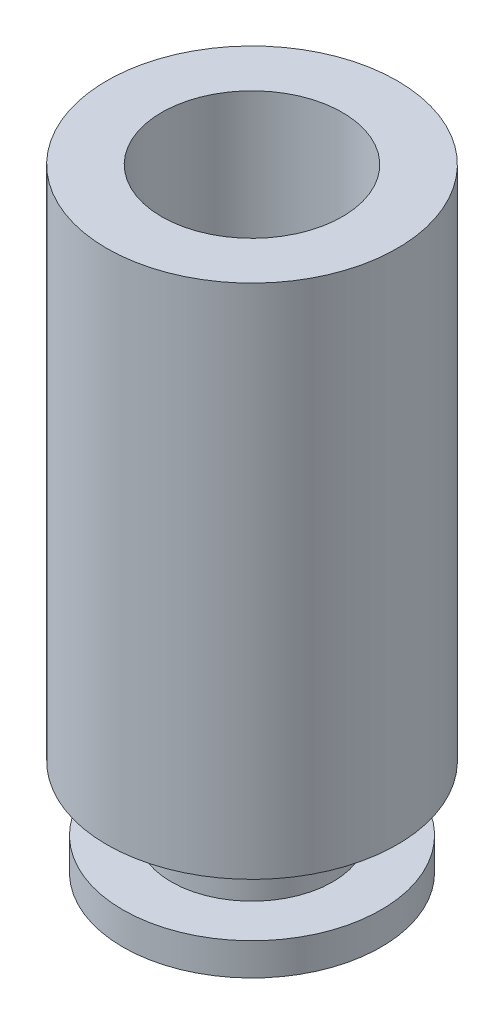
from build123d import *

# Parameters (mm, degrees)
SKETCH1_R           = 2.25
BOSS_EXTRUDE1_DEPTH = 8
SKETCH1_3_R         = 1.375
BOSS_EXTRUDE2_DEPTH = 1
SKETCH5_R           = 1.25
BOSS_EXTRUDE3_DEPTH = 1
SKETCH6_R           = 2
BOSS_EXTRUDE4_DEPTH = 0.5
SKETCH12_R          = 1.4
CUT_EXTRUDE1_DEPTH  = 7.5


with BuildPart() as part:
    # Sketch1 → Boss-Extrude1 (new body)
    with BuildSketch(Plane(origin=(0, 0, 0), x_dir=(1, 0, 0), z_dir=(0, 1, 0))):
        with Locations((-0.522013312, 0.511138034)):
            Circle(SKETCH1_R)
    extrude(amount=BOSS_EXTRUDE1_DEPTH)

    # Sketch1_3 → Boss-Extrude2 (add)
    with BuildSketch(Plane(origin=(0, 0, 0), x_dir=(1, 0, 0), z_dir=(0, 1, 0))):
        with Locations((-0.522013312, 0.511138034)):
            Circle(SKETCH1_3_R)
    extrude(amount=BOSS_EXTRUDE2_DEPTH)

    # Sketch5 → Boss-Extrude3 (add)
    with BuildSketch(Plane.XZ):
        with Locations((-0.522013312, -0.511138034)):
            Circle(SKETCH5_R)
    extrude(amount=BOSS_EXTRUDE3_DEPTH)

    # Sketch6 → Boss-Extrude4 (add)
    with BuildSketch(Plane.XZ.offset(1)):
        with Locations((-0.522013312, -0.511138034)):
            Circle(SKETCH6_R)
    extrude(amount=BOSS_EXTRUDE4_DEPTH)

    # Sketch12 → Cut-Extrude1 (cut)
    with BuildSketch(Plane(origin=(0, 8, 0), x_dir=(1, 0, 0), z_dir=(0, 1, 0))):
        with Locations((-0.522013312, 0.511138034)):
            Circle(SKETCH12_R)
    extrude(amount=-CUT_EXTRUDE1_DEPTH, mode=Mode.SUBTRACT)


solid = part.part
